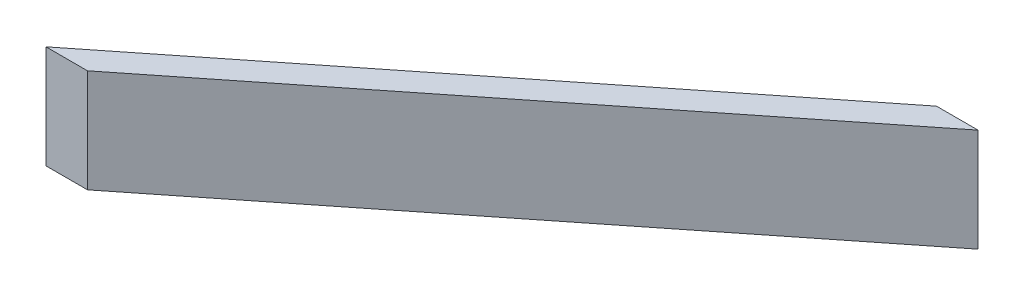
from build123d import *

# Parameters (mm, degrees)
AUFSATZ_LINEAR_AUSTRAGEN1_DEPTH = 10


with BuildPart() as part:
    # Skizze2 → Aufsatz-Linear austragen1 (new body, symmetric)
    with BuildSketch(Plane(origin=(0, 0, 0), x_dir=(1, 0, 0), z_dir=(0, 1, 0))):
        Polygon((-50, -76.395913013), (46.325912394, 0), (54.372360184, 0), (-41.95355221, -76.395913013), align=None)
    extrude(amount=AUFSATZ_LINEAR_AUSTRAGEN1_DEPTH, both=True)


solid = part.part
